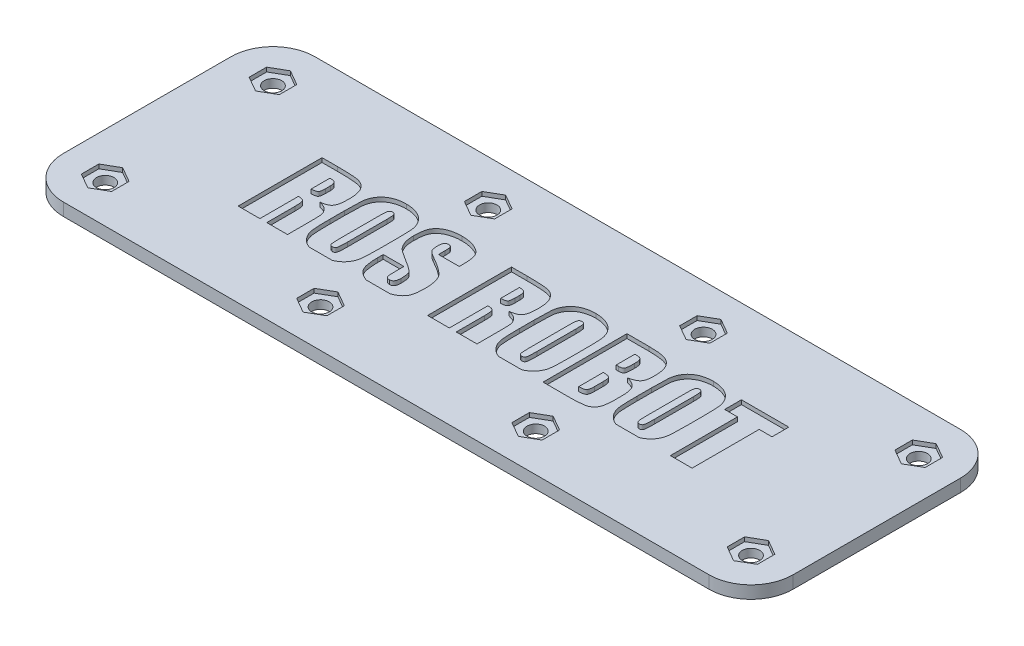
from build123d import *

# Parameters (mm, degrees)
SKETCH1_W           = 174
SKETCH1_H           = 60
BOSS_EXTRUDE1_DEPTH = 3
SKETCH2_R           = 2.09
CUT_EXTRUDE1_DEPTH  = 4
FILLET1_R           = 10
CUT_EXTRUDE2_DEPTH  = 1
CUT_EXTRUDE3_DEPTH  = 1


with BuildPart() as part:
    # Sketch1 → Boss-Extrude1 (new body)
    with BuildSketch(Plane(origin=(0, 0, 0), x_dir=(1, 0, 0), z_dir=(0, 1, 0))):
        Rectangle(SKETCH1_W, SKETCH1_H)
    extrude(amount=BOSS_EXTRUDE1_DEPTH)

    # Sketch2 → Cut-Extrude1 (cut, through all)
    with BuildSketch(Plane(origin=(0, 3, 0), x_dir=(1, 0, 0), z_dir=(0, 1, 0))):
        with Locations((-76.995, 20)):
            Circle(SKETCH2_R)
        with Locations((-25.665, 20)):
            Circle(SKETCH2_R)
        with Locations((25.665, 20)):
            Circle(SKETCH2_R)
        with Locations((76.995, 20)):
            Circle(SKETCH2_R)
    cut_extrude1 = extrude(amount=-CUT_EXTRUDE1_DEPTH, mode=Mode.SUBTRACT)

    # Mirror1: Cut-Extrude1 across plane
    add(cut_extrude1.mirror(Plane.XY), mode=Mode.SUBTRACT)

    # Fillet1
    fillet1_edges = [part.edges().sort_by_distance(p)[0] for p in [
        (87, 1.5, 30),
        (-87, 1.5, 30),
        (-87, 1.5, -30),
        (87, 1.5, -30),
    ]]
    fillet(fillet1_edges, radius=FILLET1_R)

    # Sketch3 → Cut-Extrude2 (cut)
    with BuildSketch(Plane(origin=(0, 3, 0), x_dir=(1, 0, 0), z_dir=(0, 1, 0))):
        with BuildLine():
            Line((-55.294117647, 10), (-55.294117647, -10))
            Line((-55.294117647, -10), (-50.117647059, -10))
            Line((-50.117647059, -10), (-50.117647059, -0.823529412))
            add(Edge.make_bspline(
                [(-48.470588235, -3.235294118), (-48.472761242, -2.989057045), (-48.472387298, -2.639023284), (-48.505158342, -2.198133437), (-48.532479629, -1.92557618), (-48.569704298, -1.691279038), (-48.610487711, -1.495733015), (-48.665731057, -1.339045986), (-48.72892158, -1.214559745), (-48.811250352, -1.114048439), (-48.923249449, -1.039006456), (-49.055008244, -0.967790447), (-49.216553319, -0.913344326), (-49.404406892, -0.87518001), (-49.706887916, -0.834016934), (-49.948360167, -0.824906739), (-50.117647059, -0.823529412)],
                knots=[0, 0, 0, 0, 0.208712059, 0.296134584, 0.374433717, 0.440652749, 0.497064647, 0.543362023, 0.580977914, 0.614871505, 0.652040686, 0.69429784, 0.741574127, 0.795734674, 0.856514492, 1, 1, 1, 1], degree=3))
            Line((-48.470588235, -3.235294118), (-48.470588235, -10))
            Line((-48.470588235, -10), (-43.529411765, -10))
            Line((-43.529411765, -10), (-43.529411765, -4.658088235))
            add(Edge.make_bspline(
                [(-46.408088235, 0.573529412), (-46.169175195, 0.50822747), (-45.822797374, 0.415734606), (-45.392366575, 0.25367086), (-45.117566143, 0.123930771), (-44.870917189, -0.007492588), (-44.65785979, -0.150360385), (-44.475013905, -0.301624252), (-44.280128786, -0.508899378), (-44.084325942, -0.769865918), (-43.889130105, -1.074726742), (-43.748038737, -1.369657122), (-43.665206597, -1.619897087), (-43.628706333, -1.846302243), (-43.597806292, -2.071507013), (-43.579140796, -2.357697691), (-43.560358753, -2.703267668), (-43.546626536, -3.107776257), (-43.529565282, -3.765806928), (-43.534845869, -4.289262628), (-43.529411765, -4.658088235)],
                knots=[0, 0, 0, 0, 0.110230182, 0.159227155, 0.204340897, 0.245320208, 0.283417653, 0.318243371, 0.350628895, 0.409719639, 0.463107288, 0.511383408, 0.554826309, 0.579739697, 0.613274558, 0.655916727, 0.707227072, 0.767225961, 0.835926031, 1, 1, 1, 1], degree=3))
            add(Edge.make_bspline(
                [(-43.529411765, 4.617647059), (-43.523559379, 4.265343442), (-43.547444952, 3.759926021), (-43.602480895, 3.118174034), (-43.67103257, 2.70757313), (-43.748929488, 2.343067112), (-43.846868698, 2.023021074), (-43.966655354, 1.751430904), (-44.105783368, 1.520874413), (-44.274381424, 1.32692517), (-44.474656502, 1.156423758), (-44.713189671, 1.010798238), (-44.984161555, 0.881436662), (-45.289554301, 0.77180459), (-45.764929016, 0.650898651), (-46.14354858, 0.594911695), (-46.408088235, 0.573529412)],
                knots=[0, 0, 0, 0, 0.183790359, 0.264137372, 0.336086755, 0.400975565, 0.458649469, 0.51049186, 0.555594521, 0.598692018, 0.644079697, 0.692369191, 0.744168131, 0.800636925, 0.861471696, 1, 1, 1, 1], degree=3))
            add(Edge.make_bspline(
                [(-51.566176471, 10), (-50.993819944, 10.002073268), (-50.173782937, 9.992522011), (-49.130967301, 9.961770188), (-48.461579038, 9.934349846), (-47.867125834, 9.893765625), (-47.348485673, 9.846902044), (-46.905287107, 9.793813546), (-46.526534008, 9.727924289), (-46.192709029, 9.642203621), (-45.884608598, 9.529610049), (-45.589803188, 9.3956181), (-45.311726309, 9.228198446), (-45.052332013, 9.031642664), (-44.802348856, 8.815602269), (-44.574834978, 8.564597704), (-44.355921653, 8.290441128), (-44.158035206, 7.977684947), (-43.990685169, 7.6226227), (-43.847046859, 7.226287928), (-43.730527587, 6.786918244), (-43.640302786, 6.30511939), (-43.54780148, 5.579003966), (-43.534831682, 5.009887783), (-43.529411765, 4.617647059)],
                knots=[0, 0, 0, 0, 0.148881435, 0.213302999, 0.271376625, 0.323137581, 0.368275921, 0.406826982, 0.439217091, 0.468211877, 0.496345732, 0.524443445, 0.552325136, 0.580568943, 0.609027807, 0.638127546, 0.668547056, 0.700208954, 0.734143472, 0.770447799, 0.809729999, 0.852243566, 0.897872275, 1, 1, 1, 1], degree=3))
            Line((-51.566176471, 10), (-55.294117647, 10))
        make_face()
        with BuildLine():
            Line((-50.117647059, 2.235294118), (-50.117647059, 6.705882353))
            add(Edge.make_bspline(
                [(-48.470588235, 5.154411765), (-48.473249493, 5.418336948), (-48.491488459, 5.788234319), (-48.648984539, 6.208983424), (-48.813415334, 6.422021915), (-49.050216126, 6.552252293), (-49.479623299, 6.691331049), (-49.853765331, 6.700787332), (-50.117647059, 6.705882353)],
                knots=[0, 0, 0, 0, 0.296724354, 0.405999103, 0.497474067, 0.590179394, 0.702696619, 1, 1, 1, 1], degree=3))
            Line((-48.470588235, 5.154411765), (-48.470588235, 4.047794118))
            add(Edge.make_bspline(
                [(-50.117647059, 2.235294118), (-49.857557508, 2.233760348), (-49.495937601, 2.254180117), (-49.069683976, 2.35845805), (-48.867432147, 2.445644692), (-48.745704681, 2.557108502), (-48.667446357, 2.67024801), (-48.608188606, 2.82039897), (-48.557138221, 3.001544455), (-48.518214815, 3.215789117), (-48.475786771, 3.567218376), (-48.476158421, 3.849445469), (-48.470588235, 4.047794118)],
                knots=[0, 0, 0, 0, 0.263190412, 0.361520604, 0.442777778, 0.481272857, 0.526534855, 0.58025477, 0.643242407, 0.716208439, 0.799608844, 1, 1, 1, 1], degree=3))
        make_face(mode=Mode.SUBTRACT)
        with BuildLine():
            add(Edge.make_bspline(
                [(-38.388878703, -10), (-38.434708827, -9.982163901), (-38.689460697, -9.879507335), (-39.133624425, -9.665315535), (-39.678873646, -9.294141109), (-40.171633435, -8.868283302), (-40.586226394, -8.369291591), (-40.935270304, -7.832606995), (-41.206143721, -7.264803658), (-41.399454988, -6.675518554), (-41.495658764, -6.158697296), (-41.535688973, -5.707416893), (-41.565020939, -5.309067923), (-41.590029598, -4.851864522), (-41.612869809, -4.338406349), (-41.625933126, -3.765971588), (-41.641510116, -2.887325956), (-41.645761355, -2.198537053), (-41.647058824, -1.720588235)],
                knots=[0.225245668, 0.225245668, 0.225245668, 0.225245668, 0.237119462, 0.291547555, 0.344026935, 0.396061673, 0.448382925, 0.500209986, 0.550407591, 0.599943185, 0.649656355, 0.677028621, 0.709391549, 0.746167788, 0.787661399, 0.833573904, 0.884512765, 1, 1, 1, 1], degree=3))
            Line((-38.388878703, -10), (-32.905924085, -10))
            add(Edge.make_bspline(
                [(-29.647058824, -1.720588235), (-29.651493202, -2.187493055), (-29.648984904, -2.861564549), (-29.662811581, -3.723176582), (-29.683877999, -4.286757999), (-29.699032895, -4.794372306), (-29.725932686, -5.247761941), (-29.754578926, -5.646171759), (-29.796123241, -6.101647454), (-29.881927971, -6.624914293), (-30.068550138, -7.219511222), (-30.333102923, -7.785177502), (-30.665158797, -8.321353326), (-31.070693344, -8.812589913), (-31.546395378, -9.246149672), (-32.087746262, -9.619888631), (-32.553134288, -9.856872129), (-32.833767769, -9.972014325), (-32.905924085, -10)],
                knots=[0, 0, 0, 0, 0.112808662, 0.162854343, 0.208179017, 0.249065094, 0.285542064, 0.317901769, 0.345566, 0.396043361, 0.445675688, 0.495616157, 0.546553387, 0.597655569, 0.64900077, 0.701564226, 0.756120432, 0.774811337, 0.774811337, 0.774811337, 0.774811337], degree=3))
            Line((-29.647058824, -1.720588235), (-29.647058824, 1.720588235))
            add(Edge.make_bspline(
                [(-35.647058824, 10.470588235), (-35.137575905, 10.469671201), (-34.387789186, 10.412760966), (-33.431941344, 10.186217725), (-32.774834164, 9.955436447), (-32.162941474, 9.66465689), (-31.615877667, 9.296369489), (-31.126285412, 8.866806687), (-30.711083667, 8.369636901), (-30.363430058, 7.831558235), (-30.087072885, 7.265823377), (-29.894586103, 6.674250061), (-29.797995226, 6.156263525), (-29.759895222, 5.70476117), (-29.722524292, 5.308199355), (-29.70625146, 4.85167531), (-29.680267762, 4.338451088), (-29.669795353, 3.76590889), (-29.643393387, 2.887460762), (-29.654649696, 2.198445293), (-29.647058824, 1.720588235)],
                knots=[0, 0, 0, 0, 0.123202067, 0.180742519, 0.236944207, 0.291252849, 0.34398818, 0.39581077, 0.448142032, 0.499979007, 0.550314461, 0.599859532, 0.649873316, 0.677250819, 0.709347809, 0.74611558, 0.787617129, 0.833538417, 0.884493047, 1, 1, 1, 1], degree=3))
            add(Edge.make_bspline(
                [(-41.647058824, 1.720588235), (-41.642479537, 2.188713716), (-41.645362429, 2.862798648), (-41.631084571, 3.724392091), (-41.610768004, 4.286786515), (-41.593370162, 4.795440173), (-41.573393836, 5.249142813), (-41.542621817, 5.647343808), (-41.502478839, 6.101980465), (-41.410876445, 6.624508136), (-41.225726568, 7.219419898), (-40.962205687, 7.784810836), (-40.626379301, 8.318154077), (-40.225023864, 8.814087979), (-39.744245108, 9.243388483), (-39.206325549, 9.621689493), (-38.599037538, 9.926923969), (-37.936810382, 10.175524458), (-36.95178636, 10.407114958), (-36.17714782, 10.475980227), (-35.647058824, 10.470588235)],
                knots=[0, 0, 0, 0, 0.113099886, 0.162847397, 0.208170127, 0.249054449, 0.28580995, 0.317873, 0.345536044, 0.396062444, 0.445692641, 0.495630967, 0.546314995, 0.597643479, 0.649205395, 0.701523382, 0.756077247, 0.812941755, 0.872040704, 1, 1, 1, 1], degree=3))
            Line((-41.647058824, 1.720588235), (-41.647058824, -1.720588235))
        make_face()
        with BuildLine():
            Line((-36.470588235, -4.566176471), (-36.470588235, 4.959558824))
            add(Edge.make_bspline(
                [(-35.621323529, 7.176470588), (-35.747602558, 7.182797441), (-35.932570128, 7.138559035), (-36.14071198, 7.000683728), (-36.24456145, 6.877108883), (-36.313521669, 6.744569909), (-36.354014493, 6.603411175), (-36.390824537, 6.425261242), (-36.417513223, 6.207467331), (-36.445299609, 5.951569919), (-36.461170767, 5.530700778), (-36.472983376, 5.196283974), (-36.470588235, 4.959558824)],
                knots=[0, 0, 0, 0, 0.141272891, 0.207933505, 0.278501019, 0.320511285, 0.375555263, 0.443280697, 0.525522512, 0.622694993, 0.733336158, 1, 1, 1, 1], degree=3))
            add(Edge.make_bspline(
                [(-34.823529412, 4.959558824), (-34.824206202, 5.175303354), (-34.830022252, 5.482932653), (-34.843021941, 5.871602904), (-34.862219357, 6.115480155), (-34.88386874, 6.32757554), (-34.907405438, 6.508580133), (-34.940578471, 6.655852623), (-34.986221663, 6.805984555), (-35.070163571, 6.954005969), (-35.268657855, 7.143059215), (-35.4859788, 7.172463444), (-35.621323529, 7.176470588)],
                knots=[0, 0, 0, 0, 0.245381507, 0.350013726, 0.44228014, 0.523562531, 0.592561096, 0.649714338, 0.695120491, 0.770678918, 0.840725622, 1, 1, 1, 1], degree=3))
            Line((-34.823529412, 4.959558824), (-34.823529412, -4.415441176))
            add(Edge.make_bspline(
                [(-35.658088235, -7.176470588), (-35.506517968, -7.179093019), (-35.270579792, -7.129538142), (-35.057506035, -6.90767097), (-34.978675403, -6.727494998), (-34.93172423, -6.545832046), (-34.90568827, -6.363169473), (-34.879563331, -6.140135689), (-34.857350345, -5.875330263), (-34.844662634, -5.568704581), (-34.82859228, -5.07734288), (-34.824982646, -4.688733938), (-34.823529412, -4.415441176)],
                knots=[0, 0, 0, 0, 0.145035585, 0.209346918, 0.281953002, 0.327186926, 0.385477675, 0.455016533, 0.53818829, 0.634996402, 0.743261766, 1, 1, 1, 1], degree=3))
            add(Edge.make_bspline(
                [(-36.470588235, -4.566176471), (-36.466064103, -4.834553498), (-36.468857925, -5.215756676), (-36.455213652, -5.695131762), (-36.434073907, -5.990199181), (-36.419382085, -6.243241553), (-36.392829647, -6.454082367), (-36.364986269, -6.62251498), (-36.325211771, -6.78643941), (-36.242673887, -6.945563097), (-36.032036263, -7.143111825), (-35.802728696, -7.175688722), (-35.658088235, -7.176470588)],
                knots=[0, 0, 0, 0, 0.263965983, 0.374910105, 0.471520145, 0.554902094, 0.624118814, 0.680393612, 0.722784308, 0.789641701, 0.853612109, 1, 1, 1, 1], degree=3))
        make_face(mode=Mode.SUBTRACT)
        with BuildLine():
            add(Edge.make_bspline(
                [(-24.797933292, -10), (-24.921932393, -9.95471233), (-25.178630769, -9.853998955), (-25.549413404, -9.667641606), (-25.909341849, -9.459149009), (-26.239594792, -9.236779668), (-26.536792154, -8.999076642), (-26.802666174, -8.749624779), (-27.036252757, -8.484168872), (-27.233897492, -8.202723929), (-27.407075044, -7.912631545), (-27.539510276, -7.599452016), (-27.648684303, -7.26533218), (-27.746477149, -6.902596374), (-27.819338969, -6.506054533), (-27.887643483, -6.077356452), (-27.937301298, -5.615945519), (-27.98785038, -4.93600571), (-27.999768306, -4.409440994), (-28, -4.047794118)],
                knots=[0.286183202, 0.286183202, 0.286183202, 0.286183202, 0.324626854, 0.366463546, 0.406943511, 0.445764357, 0.48234487, 0.51770616, 0.551866298, 0.585155068, 0.617796039, 0.650099364, 0.683972791, 0.720174947, 0.759459361, 0.801373688, 0.846639763, 0.894618483, 1, 1, 1, 1], degree=3))
            Line((-24.797933292, -10), (-19.023347482, -10))
            add(Edge.make_bspline(
                [(-16, -4.875), (-15.998014857, -5.212265147), (-16.014101673, -5.701000746), (-16.069510311, -6.326928981), (-16.122472292, -6.743414513), (-16.196896507, -7.123612972), (-16.283689692, -7.469046697), (-16.385871847, -7.780925616), (-16.507930807, -8.061015007), (-16.654822165, -8.317315274), (-16.830122643, -8.557450899), (-17.032306907, -8.789565117), (-17.265554656, -9.010265677), (-17.528122043, -9.221337336), (-17.822490556, -9.417622448), (-18.145436019, -9.60646373), (-18.543697705, -9.810536832), (-18.843273457, -9.934229978), (-19.023347482, -10)],
                knots=[0, 0, 0, 0, 0.107306702, 0.155458913, 0.199906966, 0.240819393, 0.278648167, 0.313173616, 0.345123698, 0.375689955, 0.406966721, 0.43957622, 0.473499712, 0.509002183, 0.546637541, 0.585960101, 0.627987093, 0.68893065, 0.68893065, 0.68893065, 0.68893065], degree=3))
            add(Edge.make_bspline(
                [(-16.9375, -0.566176471), (-16.77003858, -0.806043702), (-16.558891693, -1.211465721), (-16.357268829, -1.810580448), (-16.225991682, -2.324256078), (-16.123687479, -2.890649038), (-16.024389707, -3.744627839), (-15.999987273, -4.413744653), (-16, -4.875)],
                knots=[0, 0, 0, 0, 0.19599711, 0.304678492, 0.423526134, 0.551406495, 0.69050554, 1, 1, 1, 1], degree=3))
            add(Edge.make_bspline(
                [(-21.529411765, 2.783088235), (-20.970305965, 2.473367773), (-20.172909867, 2.018375264), (-19.189740388, 1.388063598), (-18.573813667, 0.956308764), (-18.038870295, 0.552231412), (-17.480460132, 0.067679288), (-17.119384349, -0.302443276), (-16.9375, -0.566176471)],
                knots=[0, 0, 0, 0, 0.335277756, 0.481299959, 0.612364063, 0.729738585, 0.83271341, 1, 1, 1, 1], degree=3))
            add(Edge.make_bspline(
                [(-23.044117647, 4.007352941), (-22.995337919, 3.908726816), (-22.89204074, 3.763485988), (-22.716456053, 3.578339598), (-22.539134867, 3.431720611), (-22.334418219, 3.274066191), (-21.999638416, 3.049218613), (-21.722308394, 2.892754352), (-21.529411765, 2.783088235)],
                knots=[0, 0, 0, 0, 0.16675308, 0.269572473, 0.387215686, 0.516181657, 0.662459423, 1, 1, 1, 1], degree=3))
            add(Edge.make_bspline(
                [(-23.294117647, 5.573529412), (-23.296326908, 5.268536496), (-23.266606811, 4.735456987), (-23.143358219, 4.213860364), (-23.044117647, 4.007352941)],
                knots=[0, 0, 0, 0, 0.572651319, 1, 1, 1, 1], degree=3))
            add(Edge.make_bspline(
                [(-22.272058824, 7.176470588), (-22.422382216, 7.175318321), (-22.652559624, 7.133916453), (-22.898626556, 6.956363272), (-23.049357016, 6.777858689), (-23.163822977, 6.547345801), (-23.266997244, 6.142731079), (-23.300706927, 5.81087743), (-23.294117647, 5.573529412)],
                knots=[0, 0, 0, 0, 0.212113464, 0.31285869, 0.41856281, 0.535755935, 0.669150346, 1, 1, 1, 1], degree=3))
            add(Edge.make_bspline(
                [(-21.411764706, 5.463235294), (-21.412660836, 5.76472571), (-21.419668964, 6.171441157), (-21.505234267, 6.643084782), (-21.592726876, 6.863837137), (-21.719331543, 7.011621902), (-21.93796031, 7.146205292), (-22.136537492, 7.180330892), (-22.272058824, 7.176470588)],
                knots=[0, 0, 0, 0, 0.412842651, 0.553103389, 0.653610262, 0.733180376, 0.814494127, 1, 1, 1, 1], degree=3))
            Line((-21.411764706, 5.463235294), (-21.411764706, 3.882352941))
            Line((-21.411764706, 3.882352941), (-16.470588235, 3.882352941))
            Line((-16.470588235, 3.882352941), (-16.470588235, 4.6875))
            add(Edge.make_bspline(
                [(-22.433823529, 10.470588235), (-22.099355515, 10.465692072), (-21.605258314, 10.457850903), (-20.964766066, 10.377003258), (-20.510624153, 10.311996602), (-20.077185548, 10.213326449), (-19.66128427, 10.101842278), (-19.265923032, 9.964972533), (-18.892354157, 9.80679878), (-18.543176622, 9.63523955), (-18.21927313, 9.457507477), (-17.933690102, 9.258320673), (-17.668603796, 9.061328877), (-17.446057148, 8.839147392), (-17.242755176, 8.616987473), (-17.078595902, 8.376988569), (-16.940479561, 8.122327535), (-16.830854918, 7.838398109), (-16.730671215, 7.519755184), (-16.652900473, 7.154877719), (-16.581526247, 6.748162273), (-16.532829806, 6.294893947), (-16.481907954, 5.603934437), (-16.470960066, 5.062596294), (-16.470588235, 4.6875)],
                knots=[0, 0, 0, 0, 0.103080501, 0.151693764, 0.19864086, 0.244219301, 0.288418896, 0.331125316, 0.372879908, 0.413199037, 0.450863398, 0.486435308, 0.520312869, 0.552324632, 0.583055083, 0.61287614, 0.641566415, 0.672036474, 0.706397787, 0.744284381, 0.786763637, 0.833460023, 0.88452287, 1, 1, 1, 1], degree=3))
            add(Edge.make_bspline(
                [(-28.235294118, 4.786764706), (-28.229904379, 5.148252189), (-28.222936356, 5.672108777), (-28.155500003, 6.342020821), (-28.091071009, 6.786560757), (-28.006245663, 7.192892425), (-27.906291969, 7.561802534), (-27.780339706, 7.889279126), (-27.639202273, 8.183003162), (-27.474416935, 8.448602585), (-27.285392797, 8.693163012), (-27.079329609, 8.929597443), (-26.842812469, 9.143134685), (-26.586901064, 9.347943873), (-26.308886347, 9.538843121), (-26.005284687, 9.71100803), (-25.56649327, 9.9259027), (-24.965093143, 10.146603568), (-23.885130997, 10.411380502), (-23.0240668, 10.470239671), (-22.433823529, 10.470588235)],
                knots=[0, 0, 0, 0, 0.115094371, 0.166420003, 0.214115061, 0.257929727, 0.298417601, 0.335563099, 0.369390983, 0.401957355, 0.434786392, 0.467650138, 0.501587937, 0.535990613, 0.571893796, 0.608743473, 0.646930183, 0.727243377, 0.811970216, 1, 1, 1, 1], degree=3))
            add(Edge.make_bspline(
                [(-23.977941176, -1.323529412), (-24.294511538, -1.131326069), (-24.746909058, -0.853590336), (-25.315671043, -0.487028948), (-25.67659423, -0.24587788), (-25.996353777, -0.028044889), (-26.270684916, 0.16966582), (-26.504121427, 0.345288928), (-26.757215062, 0.55675599), (-27.030741585, 0.83859719), (-27.322185819, 1.219607774), (-27.582496129, 1.657177863), (-27.816766684, 2.149881455), (-28.010855914, 2.707861537), (-28.187017003, 3.591825136), (-28.241857015, 4.295407074), (-28.235294118, 4.786764706)],
                knots=[0, 0, 0, 0, 0.139496641, 0.199928992, 0.254849813, 0.302989801, 0.34564832, 0.382206877, 0.412998417, 0.469793972, 0.529711152, 0.593277583, 0.661207422, 0.734923814, 0.815133371, 1, 1, 1, 1], degree=3))
            add(Edge.make_bspline(
                [(-21.422794118, -3.125), (-21.527957196, -3.006841113), (-21.723413246, -2.83159541), (-22.028603612, -2.599028882), (-22.320702285, -2.381572104), (-22.665243802, -2.146757406), (-23.218217274, -1.78459162), (-23.666055556, -1.51485041), (-23.977941176, -1.323529412)],
                knots=[0, 0, 0, 0, 0.151175118, 0.250666735, 0.367275691, 0.499710264, 0.649705358, 1, 1, 1, 1], degree=3))
            add(Edge.make_bspline(
                [(-20.941176471, -5.507352941), (-20.94089679, -5.230116988), (-20.953296851, -4.833443943), (-21.001304147, -4.330418615), (-21.057491677, -4.01300655), (-21.120630168, -3.732359951), (-21.227908005, -3.432060954), (-21.330213724, -3.231067844), (-21.422794118, -3.125)],
                knots=[0, 0, 0, 0, 0.336674091, 0.481823819, 0.613233997, 0.728041636, 0.830672596, 1, 1, 1, 1], degree=3))
            add(Edge.make_bspline(
                [(-22.055147059, -7.176470588), (-21.885541571, -7.181042695), (-21.636919353, -7.129696315), (-21.360636518, -6.948074167), (-21.204916613, -6.755008193), (-21.081823083, -6.513814138), (-20.968209931, -6.094777196), (-20.941233932, -5.750234712), (-20.941176471, -5.507352941)],
                knots=[0, 0, 0, 0, 0.223295666, 0.324626749, 0.430189395, 0.546595578, 0.679609164, 1, 1, 1, 1], degree=3))
            add(Edge.make_bspline(
                [(-23.058823529, -5.297794118), (-23.061330484, -5.479444625), (-23.049017381, -5.737799236), (-23.033549614, -6.065711905), (-23.004726, -6.271102852), (-22.979951789, -6.451745816), (-22.937095221, -6.603092758), (-22.895293432, -6.730061315), (-22.827664593, -6.862832994), (-22.711681339, -6.993662718), (-22.454353006, -7.150620917), (-22.215061065, -7.172923046), (-22.055147059, -7.176470588)],
                knots=[0, 0, 0, 0, 0.221449353, 0.31585969, 0.400263121, 0.474516094, 0.538002798, 0.591926172, 0.637412015, 0.719012888, 0.801608182, 1, 1, 1, 1], degree=3))
            Line((-23.058823529, -5.297794118), (-23.058823529, -2.705882353))
            Line((-23.058823529, -2.705882353), (-28, -2.705882353))
            Line((-28, -2.705882353), (-28, -4.047794118))
        make_face()
        with BuildLine():
            Line((-10.117647059, 10), (-10.117647059, -10))
            Line((-10.117647059, -10), (-4.941176471, -10))
            Line((-4.941176471, -10), (-4.941176471, -0.823529412))
            add(Edge.make_bspline(
                [(-3.294117647, -3.235294118), (-3.296290654, -2.989057045), (-3.295916709, -2.639023284), (-3.328687754, -2.198133437), (-3.356009041, -1.92557618), (-3.39323371, -1.691279038), (-3.434017123, -1.495733015), (-3.489260469, -1.339045986), (-3.552450992, -1.214559745), (-3.634779763, -1.114048439), (-3.74677886, -1.039006456), (-3.878537656, -0.967790447), (-4.040082731, -0.913344326), (-4.227936304, -0.87518001), (-4.530417327, -0.834016934), (-4.771889579, -0.824906739), (-4.941176471, -0.823529412)],
                knots=[0, 0, 0, 0, 0.208712059, 0.296134584, 0.374433717, 0.440652749, 0.497064647, 0.543362023, 0.580977914, 0.614871505, 0.652040686, 0.69429784, 0.741574127, 0.795734674, 0.856514492, 1, 1, 1, 1], degree=3))
            Line((-3.294117647, -3.235294118), (-3.294117647, -10))
            Line((-3.294117647, -10), (1.647058824, -10))
            Line((1.647058824, -10), (1.647058824, -4.658088235))
            add(Edge.make_bspline(
                [(-1.231617647, 0.573529412), (-0.992704607, 0.50822747), (-0.646326786, 0.415734606), (-0.215895987, 0.25367086), (0.058904445, 0.123930771), (0.3055534, -0.007492588), (0.518610798, -0.150360385), (0.701456683, -0.301624252), (0.896341803, -0.508899378), (1.092144646, -0.769865918), (1.287340483, -1.074726742), (1.428431851, -1.369657122), (1.511263992, -1.619897087), (1.547764255, -1.846302243), (1.578664296, -2.071507013), (1.597329792, -2.357697691), (1.616111835, -2.703267668), (1.629844053, -3.107776257), (1.646905306, -3.765806928), (1.641624719, -4.289262628), (1.647058824, -4.658088235)],
                knots=[0, 0, 0, 0, 0.110230182, 0.159227155, 0.204340897, 0.245320208, 0.283417653, 0.318243371, 0.350628895, 0.409719639, 0.463107288, 0.511383408, 0.554826309, 0.579739697, 0.613274558, 0.655916727, 0.707227072, 0.767225961, 0.835926031, 1, 1, 1, 1], degree=3))
            add(Edge.make_bspline(
                [(1.647058824, 4.617647059), (1.652911209, 4.265343442), (1.629025636, 3.759926021), (1.573989693, 3.118174034), (1.505438018, 2.70757313), (1.4275411, 2.343067112), (1.32960189, 2.023021074), (1.209815234, 1.751430904), (1.070687221, 1.520874413), (0.902089165, 1.32692517), (0.701814086, 1.156423758), (0.463280917, 1.010798238), (0.192309033, 0.881436662), (-0.113083713, 0.77180459), (-0.588458428, 0.650898651), (-0.967077992, 0.594911695), (-1.231617647, 0.573529412)],
                knots=[0, 0, 0, 0, 0.183790359, 0.264137372, 0.336086755, 0.400975565, 0.458649469, 0.51049186, 0.555594521, 0.598692018, 0.644079697, 0.692369191, 0.744168131, 0.800636925, 0.861471696, 1, 1, 1, 1], degree=3))
            add(Edge.make_bspline(
                [(-6.389705882, 10), (-5.817349355, 10.002073268), (-4.997312349, 9.992522011), (-3.954496712, 9.961770188), (-3.28510845, 9.934349846), (-2.690655246, 9.893765625), (-2.172015085, 9.846902044), (-1.728816518, 9.793813546), (-1.35006342, 9.727924289), (-1.016238441, 9.642203621), (-0.70813801, 9.529610049), (-0.4133326, 9.3956181), (-0.135255721, 9.228198446), (0.124138575, 9.031642664), (0.374121732, 8.815602269), (0.60163561, 8.564597704), (0.820548935, 8.290441128), (1.018435383, 7.977684947), (1.185785419, 7.6226227), (1.329423729, 7.226287928), (1.445943001, 6.786918244), (1.536167802, 6.30511939), (1.628669108, 5.579003966), (1.641638907, 5.009887783), (1.647058824, 4.617647059)],
                knots=[0, 0, 0, 0, 0.148881435, 0.213302999, 0.271376625, 0.323137581, 0.368275921, 0.406826982, 0.439217091, 0.468211877, 0.496345732, 0.524443445, 0.552325136, 0.580568943, 0.609027807, 0.638127546, 0.668547056, 0.700208954, 0.734143472, 0.770447799, 0.809729999, 0.852243566, 0.897872275, 1, 1, 1, 1], degree=3))
            Line((-6.389705882, 10), (-10.117647059, 10))
        make_face()
        with BuildLine():
            Line((-4.941176471, 2.235294118), (-4.941176471, 6.705882353))
            add(Edge.make_bspline(
                [(-3.294117647, 5.154411765), (-3.296778905, 5.418336948), (-3.315017871, 5.788234319), (-3.472513951, 6.208983424), (-3.636944745, 6.422021915), (-3.873745538, 6.552252293), (-4.303152711, 6.691331049), (-4.677294743, 6.700787332), (-4.941176471, 6.705882353)],
                knots=[0, 0, 0, 0, 0.296724354, 0.405999103, 0.497474067, 0.590179394, 0.702696619, 1, 1, 1, 1], degree=3))
            Line((-3.294117647, 5.154411765), (-3.294117647, 4.047794118))
            add(Edge.make_bspline(
                [(-4.941176471, 2.235294118), (-4.681086919, 2.233760348), (-4.319467013, 2.254180117), (-3.893213388, 2.35845805), (-3.690961559, 2.445644692), (-3.569234093, 2.557108502), (-3.490975769, 2.67024801), (-3.431718018, 2.82039897), (-3.380667632, 3.001544455), (-3.341744227, 3.215789117), (-3.299316183, 3.567218376), (-3.299687833, 3.849445469), (-3.294117647, 4.047794118)],
                knots=[0, 0, 0, 0, 0.263190412, 0.361520604, 0.442777778, 0.481272857, 0.526534855, 0.58025477, 0.643242407, 0.716208439, 0.799608844, 1, 1, 1, 1], degree=3))
        make_face(mode=Mode.SUBTRACT)
        with BuildLine():
            add(Edge.make_bspline(
                [(6.787591886, -10), (6.741761761, -9.982163901), (6.487009891, -9.879507335), (6.042846164, -9.665315535), (5.497596942, -9.294141109), (5.004837153, -8.868283302), (4.590244195, -8.369291591), (4.241200285, -7.832606995), (3.970326867, -7.264803658), (3.7770156, -6.675518554), (3.680811824, -6.158697296), (3.640781616, -5.707416893), (3.61144965, -5.309067923), (3.58644099, -4.851864522), (3.563600779, -4.338406349), (3.550537462, -3.765971588), (3.534960472, -2.887325956), (3.530709234, -2.198537053), (3.529411765, -1.720588235)],
                knots=[0.225245668, 0.225245668, 0.225245668, 0.225245668, 0.237119462, 0.291547555, 0.344026935, 0.396061673, 0.448382925, 0.500209986, 0.550407591, 0.599943185, 0.649656355, 0.677028621, 0.709391549, 0.746167788, 0.787661399, 0.833573904, 0.884512765, 1, 1, 1, 1], degree=3))
            Line((6.787591886, -10), (12.270546503, -10))
            add(Edge.make_bspline(
                [(15.529411765, -1.720588235), (15.524977386, -2.187493055), (15.527485684, -2.861564549), (15.513659007, -3.723176582), (15.492592589, -4.286757999), (15.477437693, -4.794372306), (15.450537902, -5.247761941), (15.421891662, -5.646171759), (15.380347347, -6.101647454), (15.294542618, -6.624914293), (15.107920451, -7.219511222), (14.843367666, -7.785177502), (14.511311791, -8.321353326), (14.105777244, -8.812589913), (13.63007521, -9.246149672), (13.088724326, -9.619888631), (12.6233363, -9.856872129), (12.342702819, -9.972014325), (12.270546503, -10)],
                knots=[0, 0, 0, 0, 0.112808662, 0.162854343, 0.208179017, 0.249065094, 0.285542064, 0.317901769, 0.345566, 0.396043361, 0.445675688, 0.495616157, 0.546553387, 0.597655569, 0.64900077, 0.701564226, 0.756120432, 0.774811337, 0.774811337, 0.774811337, 0.774811337], degree=3))
            Line((15.529411765, -1.720588235), (15.529411765, 1.720588235))
            add(Edge.make_bspline(
                [(9.529411765, 10.470588235), (10.038894684, 10.469671201), (10.788681402, 10.412760966), (11.744529245, 10.186217725), (12.401636425, 9.955436447), (13.013529114, 9.66465689), (13.560592921, 9.296369489), (14.050185177, 8.866806687), (14.465386921, 8.369636901), (14.81304053, 7.831558235), (15.089397703, 7.265823377), (15.281884485, 6.674250061), (15.378475362, 6.156263525), (15.416575366, 5.70476117), (15.453946296, 5.308199355), (15.470219128, 4.85167531), (15.496202826, 4.338451088), (15.506675236, 3.76590889), (15.533077201, 2.887460762), (15.521820892, 2.198445293), (15.529411765, 1.720588235)],
                knots=[0, 0, 0, 0, 0.123202067, 0.180742519, 0.236944207, 0.291252849, 0.34398818, 0.39581077, 0.448142032, 0.499979007, 0.550314461, 0.599859532, 0.649873316, 0.677250819, 0.709347809, 0.74611558, 0.787617129, 0.833538417, 0.884493047, 1, 1, 1, 1], degree=3))
            add(Edge.make_bspline(
                [(3.529411765, 1.720588235), (3.533991052, 2.188713716), (3.531108159, 2.862798648), (3.545386018, 3.724392091), (3.565702585, 4.286786515), (3.583100426, 4.795440173), (3.603076752, 5.249142813), (3.633848772, 5.647343808), (3.67399175, 6.101980465), (3.765594143, 6.624508136), (3.95074402, 7.219419898), (4.214264902, 7.784810836), (4.550091288, 8.318154077), (4.951446724, 8.814087979), (5.43222548, 9.243388483), (5.97014504, 9.621689493), (6.57743305, 9.926923969), (7.239660206, 10.175524458), (8.224684229, 10.407114958), (8.999322768, 10.475980227), (9.529411765, 10.470588235)],
                knots=[0, 0, 0, 0, 0.113099886, 0.162847397, 0.208170127, 0.249054449, 0.28580995, 0.317873, 0.345536044, 0.396062444, 0.445692641, 0.495630967, 0.546314995, 0.597643479, 0.649205395, 0.701523382, 0.756077247, 0.812941755, 0.872040704, 1, 1, 1, 1], degree=3))
            Line((3.529411765, 1.720588235), (3.529411765, -1.720588235))
        make_face()
        with BuildLine():
            Line((8.705882353, -4.566176471), (8.705882353, 4.959558824))
            add(Edge.make_bspline(
                [(9.555147059, 7.176470588), (9.428868031, 7.182797441), (9.24390046, 7.138559035), (9.035758608, 7.000683728), (8.931909138, 6.877108883), (8.862948919, 6.744569909), (8.822456095, 6.603411175), (8.785646052, 6.425261242), (8.758957365, 6.207467331), (8.73117098, 5.951569919), (8.715299821, 5.530700778), (8.703487212, 5.196283974), (8.705882353, 4.959558824)],
                knots=[0, 0, 0, 0, 0.141272891, 0.207933505, 0.278501019, 0.320511285, 0.375555263, 0.443280697, 0.525522512, 0.622694993, 0.733336158, 1, 1, 1, 1], degree=3))
            add(Edge.make_bspline(
                [(10.352941176, 4.959558824), (10.352264386, 5.175303354), (10.346448336, 5.482932653), (10.333448647, 5.871602904), (10.314251231, 6.115480155), (10.292601849, 6.32757554), (10.26906515, 6.508580133), (10.235892117, 6.655852623), (10.190248925, 6.805984555), (10.106307017, 6.954005969), (9.907812734, 7.143059215), (9.690491789, 7.172463444), (9.555147059, 7.176470588)],
                knots=[0, 0, 0, 0, 0.245381507, 0.350013726, 0.44228014, 0.523562531, 0.592561096, 0.649714338, 0.695120491, 0.770678918, 0.840725622, 1, 1, 1, 1], degree=3))
            Line((10.352941176, 4.959558824), (10.352941176, -4.415441176))
            add(Edge.make_bspline(
                [(9.518382353, -7.176470588), (9.66995262, -7.179093019), (9.905890797, -7.129538142), (10.118964553, -6.90767097), (10.197795186, -6.727494998), (10.244746358, -6.545832046), (10.270782318, -6.363169473), (10.296907257, -6.140135689), (10.319120243, -5.875330263), (10.331807954, -5.568704581), (10.347878308, -5.07734288), (10.351487943, -4.688733938), (10.352941176, -4.415441176)],
                knots=[0, 0, 0, 0, 0.145035585, 0.209346918, 0.281953002, 0.327186926, 0.385477675, 0.455016533, 0.53818829, 0.634996402, 0.743261766, 1, 1, 1, 1], degree=3))
            add(Edge.make_bspline(
                [(8.705882353, -4.566176471), (8.710406485, -4.834553498), (8.707612663, -5.215756676), (8.721256936, -5.695131762), (8.742396681, -5.990199181), (8.757088503, -6.243241553), (8.783640941, -6.454082367), (8.811484319, -6.62251498), (8.851258818, -6.78643941), (8.933796701, -6.945563097), (9.144434325, -7.143111825), (9.373741892, -7.175688722), (9.518382353, -7.176470588)],
                knots=[0, 0, 0, 0, 0.263965983, 0.374910105, 0.471520145, 0.554902094, 0.624118814, 0.680393612, 0.722784308, 0.789641701, 0.853612109, 1, 1, 1, 1], degree=3))
        make_face(mode=Mode.SUBTRACT)
        with BuildLine():
            Line((17.411764706, 10), (17.411764706, -10))
            Line((17.411764706, -10), (23.492647059, -10))
            add(Edge.make_bspline(
                [(29.647058824, -5.242647059), (29.646934914, -5.56266215), (29.63497194, -6.026795982), (29.584977204, -6.622276843), (29.53416178, -7.01986255), (29.468709895, -7.384541811), (29.388508503, -7.716304337), (29.293798242, -8.015418252), (29.149573113, -8.363197067), (28.927560807, -8.74691581), (28.580556243, -9.13068276), (28.16551384, -9.437763787), (27.757437565, -9.624746944), (27.37556001, -9.732935722), (27.017915035, -9.80554901), (26.59446752, -9.866667644), (26.10218982, -9.911528453), (25.545803904, -9.952303985), (24.668406884, -9.993965557), (23.976672129, -9.994581299), (23.492647059, -10)],
                knots=[0, 0, 0, 0, 0.102249571, 0.148224941, 0.190863369, 0.230259752, 0.266534441, 0.299841642, 0.330380545, 0.386717901, 0.440498022, 0.494529809, 0.550587574, 0.582802206, 0.621195561, 0.667097519, 0.719418425, 0.779085769, 0.845327487, 1, 1, 1, 1], degree=3))
            Line((29.647058824, -5.242647059), (29.647058824, -3.363970588))
            add(Edge.make_bspline(
                [(26.632352941, 0.941176471), (26.906401285, 0.878367085), (27.300653812, 0.765704813), (27.787692795, 0.562963036), (28.106692167, 0.402419875), (28.388685462, 0.220959582), (28.635442208, 0.022849809), (28.848962578, -0.191232265), (29.023773677, -0.428407061), (29.173198265, -0.68773403), (29.30233921, -0.975620533), (29.406624653, -1.296799727), (29.495483711, -1.649218696), (29.564266695, -2.032454679), (29.628905941, -2.607265288), (29.645716704, -3.054823478), (29.647058824, -3.363970588)],
                knots=[0, 0, 0, 0, 0.144065397, 0.209341867, 0.269975095, 0.326732211, 0.380743663, 0.431785064, 0.481119172, 0.531178616, 0.584838818, 0.642398889, 0.703899801, 0.770874214, 0.841643912, 1, 1, 1, 1], degree=3))
            add(Edge.make_bspline(
                [(29.411764706, 4.393382353), (29.416072307, 4.126960997), (29.396065876, 3.74315812), (29.335162444, 3.256001615), (29.279024495, 2.936656591), (29.198004913, 2.651763218), (29.102620539, 2.397408381), (28.989683638, 2.175311926), (28.854039324, 1.981642317), (28.690429234, 1.812181884), (28.495593314, 1.657001481), (28.269341956, 1.510833787), (28.006048053, 1.37965403), (27.71371462, 1.248439101), (27.252486443, 1.096633591), (26.888805185, 0.993582451), (26.632352941, 0.941176471)],
                knots=[0, 0, 0, 0, 0.159593497, 0.229911515, 0.294149678, 0.353664097, 0.407125896, 0.456720642, 0.50256341, 0.548270697, 0.597357213, 0.651540418, 0.709344876, 0.773469607, 0.843372266, 1, 1, 1, 1], degree=3))
            add(Edge.make_bspline(
                [(22.716911765, 10), (23.110299522, 9.995507602), (23.681885346, 9.991990426), (24.418574897, 9.952815753), (24.913450102, 9.906680869), (25.371467166, 9.85836305), (25.790704796, 9.791308442), (26.172459453, 9.715347075), (26.520787705, 9.627485478), (26.84146812, 9.519137488), (27.144180179, 9.391831518), (27.429336701, 9.235748238), (27.697604709, 9.054575482), (27.953304968, 8.851805073), (28.191702458, 8.62386534), (28.413756391, 8.371324932), (28.621706622, 8.093999736), (28.812626294, 7.782522973), (28.973440584, 7.426443305), (29.107426233, 7.026703693), (29.222906801, 6.585043099), (29.303426476, 6.098623186), (29.390288895, 5.365364626), (29.415704121, 4.790976826), (29.411764706, 4.393382353)],
                knots=[0, 0, 0, 0, 0.114402272, 0.166147642, 0.214440873, 0.258905608, 0.300029633, 0.337835121, 0.3720588, 0.404397908, 0.436166631, 0.467419606, 0.498747648, 0.530188964, 0.562196583, 0.594510161, 0.627862043, 0.662877889, 0.700506647, 0.74118522, 0.785347679, 0.833090934, 0.884403879, 1, 1, 1, 1], degree=3))
            Line((22.716911765, 10), (17.411764706, 10))
        make_face()
        with BuildLine():
            Line((22.588235294, -6.705882353), (22.588235294, -0.823529412))
            add(Edge.make_bspline(
                [(24.470588235, -2.783088235), (24.469862246, -2.581049271), (24.468263551, -2.292776904), (24.427029649, -1.932486797), (24.404272556, -1.709794577), (24.356722032, -1.522790473), (24.308770024, -1.366819262), (24.246387911, -1.243993471), (24.173743985, -1.146988974), (24.074721587, -1.077498638), (23.954129928, -1.015414588), (23.799805517, -0.965596267), (23.616507623, -0.922557764), (23.402762748, -0.886516164), (23.057457797, -0.845450875), (22.782095648, -0.830589633), (22.588235294, -0.823529412)],
                knots=[0, 0, 0, 0, 0.182450376, 0.259089149, 0.327073499, 0.383894219, 0.4328162, 0.473836669, 0.507662291, 0.540813339, 0.581833808, 0.629708737, 0.686529456, 0.751567122, 0.825033248, 1, 1, 1, 1], degree=3))
            Line((24.470588235, -2.783088235), (24.470588235, -4.746323529))
            add(Edge.make_bspline(
                [(22.588235294, -6.705882353), (22.772111176, -6.697406963), (23.035946818, -6.686457893), (23.366082308, -6.639035107), (23.574317755, -6.600446567), (23.754734821, -6.548534402), (23.909241043, -6.49114772), (24.037582, -6.426347928), (24.139518515, -6.345276863), (24.219828968, -6.242534291), (24.290452462, -6.116974085), (24.343026299, -5.957931043), (24.390391907, -5.772581816), (24.426658548, -5.55735456), (24.460433346, -5.212848849), (24.475325771, -4.93910161), (24.470588235, -4.746323529)],
                knots=[0, 0, 0, 0, 0.168587072, 0.241054147, 0.305044923, 0.362185481, 0.412580102, 0.455716051, 0.493190485, 0.530664919, 0.574336739, 0.624343173, 0.683356267, 0.749349201, 0.823767794, 1, 1, 1, 1], degree=3))
        make_face(mode=Mode.SUBTRACT)
        with BuildLine():
            Line((22.588235294, 2.235294118), (22.588235294, 6.705882353))
            add(Edge.make_bspline(
                [(24.470588235, 4.794117647), (24.472484496, 5.063219136), (24.456102942, 5.432680133), (24.377118595, 5.876003573), (24.290960876, 6.108918073), (24.185117865, 6.287925027), (24.065630734, 6.427443722), (23.932108439, 6.534581277), (23.771096212, 6.604626256), (23.56915719, 6.646964309), (23.171954505, 6.69359434), (22.835840675, 6.701690154), (22.588235294, 6.705882353)],
                knots=[0, 0, 0, 0, 0.247893338, 0.340015611, 0.413628261, 0.475403061, 0.530639967, 0.582137883, 0.631666993, 0.690827129, 0.771639487, 1, 1, 1, 1], degree=3))
            add(Edge.make_bspline(
                [(23.161764706, 2.246323529), (23.394028214, 2.2431048), (23.720403071, 2.271138301), (24.083618428, 2.440239428), (24.230880072, 2.592576437), (24.301784115, 2.75375132), (24.348188684, 2.915615042), (24.382075121, 3.121889263), (24.415674107, 3.370608152), (24.440054223, 3.665115429), (24.465440646, 4.144235023), (24.470464317, 4.52570717), (24.470588235, 4.794117647)],
                knots=[0, 0, 0, 0, 0.207123309, 0.283931547, 0.350841284, 0.389256939, 0.439128512, 0.499893306, 0.574453467, 0.661745219, 0.761896218, 1, 1, 1, 1], degree=3))
            add(Edge.make_bspline(
                [(22.588235294, 2.235294118), (22.874959549, 2.242972169), (23.161764706, 2.246323529)],
                knots=[0, 0, 0, 1, 1, 1], degree=2))
        make_face(mode=Mode.SUBTRACT)
        with BuildLine():
            add(Edge.make_bspline(
                [(34.787591886, -10), (34.741761761, -9.982163901), (34.487009891, -9.879507335), (34.042846164, -9.665315535), (33.497596942, -9.294141109), (33.004837153, -8.868283302), (32.590244195, -8.369291591), (32.241200285, -7.832606995), (31.970326867, -7.264803658), (31.7770156, -6.675518554), (31.680811824, -6.158697296), (31.640781616, -5.707416893), (31.61144965, -5.309067923), (31.58644099, -4.851864522), (31.563600779, -4.338406349), (31.550537462, -3.765971588), (31.534960472, -2.887325956), (31.530709234, -2.198537053), (31.529411765, -1.720588235)],
                knots=[0.225245668, 0.225245668, 0.225245668, 0.225245668, 0.237119462, 0.291547555, 0.344026935, 0.396061673, 0.448382925, 0.500209986, 0.550407591, 0.599943185, 0.649656355, 0.677028621, 0.709391549, 0.746167788, 0.787661399, 0.833573904, 0.884512765, 1, 1, 1, 1], degree=3))
            Line((34.787591886, -10), (40.270546503, -10))
            add(Edge.make_bspline(
                [(43.529411765, -1.720588235), (43.524977386, -2.187493055), (43.527485684, -2.861564549), (43.513659007, -3.723176582), (43.492592589, -4.286757999), (43.477437693, -4.794372306), (43.450537902, -5.247761941), (43.421891662, -5.646171759), (43.380347347, -6.101647454), (43.294542618, -6.624914293), (43.107920451, -7.219511222), (42.843367666, -7.785177502), (42.511311791, -8.321353326), (42.105777244, -8.812589913), (41.63007521, -9.246149672), (41.088724326, -9.619888631), (40.6233363, -9.856872129), (40.342702819, -9.972014325), (40.270546503, -10)],
                knots=[0, 0, 0, 0, 0.112808662, 0.162854343, 0.208179017, 0.249065094, 0.285542064, 0.317901769, 0.345566, 0.396043361, 0.445675688, 0.495616157, 0.546553387, 0.597655569, 0.64900077, 0.701564226, 0.756120432, 0.774811337, 0.774811337, 0.774811337, 0.774811337], degree=3))
            Line((43.529411765, -1.720588235), (43.529411765, 1.720588235))
            add(Edge.make_bspline(
                [(37.529411765, 10.470588235), (38.038894684, 10.469671201), (38.788681402, 10.412760966), (39.744529245, 10.186217725), (40.401636425, 9.955436447), (41.013529114, 9.66465689), (41.560592921, 9.296369489), (42.050185177, 8.866806687), (42.465386921, 8.369636901), (42.81304053, 7.831558235), (43.089397703, 7.265823377), (43.281884485, 6.674250061), (43.378475362, 6.156263525), (43.416575366, 5.70476117), (43.453946296, 5.308199355), (43.470219128, 4.85167531), (43.496202826, 4.338451088), (43.506675236, 3.76590889), (43.533077201, 2.887460762), (43.521820892, 2.198445293), (43.529411765, 1.720588235)],
                knots=[0, 0, 0, 0, 0.123202067, 0.180742519, 0.236944207, 0.291252849, 0.34398818, 0.39581077, 0.448142032, 0.499979007, 0.550314461, 0.599859532, 0.649873316, 0.677250819, 0.709347809, 0.74611558, 0.787617129, 0.833538417, 0.884493047, 1, 1, 1, 1], degree=3))
            add(Edge.make_bspline(
                [(31.529411765, 1.720588235), (31.533991052, 2.188713716), (31.531108159, 2.862798648), (31.545386018, 3.724392091), (31.565702585, 4.286786515), (31.583100426, 4.795440173), (31.603076752, 5.249142813), (31.633848772, 5.647343808), (31.67399175, 6.101980465), (31.765594143, 6.624508136), (31.95074402, 7.219419898), (32.214264902, 7.784810836), (32.550091288, 8.318154077), (32.951446724, 8.814087979), (33.43222548, 9.243388483), (33.97014504, 9.621689493), (34.57743305, 9.926923969), (35.239660206, 10.175524458), (36.224684229, 10.407114958), (36.999322768, 10.475980227), (37.529411765, 10.470588235)],
                knots=[0, 0, 0, 0, 0.113099886, 0.162847397, 0.208170127, 0.249054449, 0.28580995, 0.317873, 0.345536044, 0.396062444, 0.445692641, 0.495630967, 0.546314995, 0.597643479, 0.649205395, 0.701523382, 0.756077247, 0.812941755, 0.872040704, 1, 1, 1, 1], degree=3))
            Line((31.529411765, 1.720588235), (31.529411765, -1.720588235))
        make_face()
        with BuildLine():
            Line((36.705882353, -4.566176471), (36.705882353, 4.959558824))
            add(Edge.make_bspline(
                [(37.555147059, 7.176470588), (37.428868031, 7.182797441), (37.24390046, 7.138559035), (37.035758608, 7.000683728), (36.931909138, 6.877108883), (36.862948919, 6.744569909), (36.822456095, 6.603411175), (36.785646052, 6.425261242), (36.758957365, 6.207467331), (36.73117098, 5.951569919), (36.715299821, 5.530700778), (36.703487212, 5.196283974), (36.705882353, 4.959558824)],
                knots=[0, 0, 0, 0, 0.141272891, 0.207933505, 0.278501019, 0.320511285, 0.375555263, 0.443280697, 0.525522512, 0.622694993, 0.733336158, 1, 1, 1, 1], degree=3))
            add(Edge.make_bspline(
                [(38.352941176, 4.959558824), (38.352264386, 5.175303354), (38.346448336, 5.482932653), (38.333448647, 5.871602904), (38.314251231, 6.115480155), (38.292601849, 6.32757554), (38.26906515, 6.508580133), (38.235892117, 6.655852623), (38.190248925, 6.805984555), (38.106307017, 6.954005969), (37.907812734, 7.143059215), (37.690491789, 7.172463444), (37.555147059, 7.176470588)],
                knots=[0, 0, 0, 0, 0.245381507, 0.350013726, 0.44228014, 0.523562531, 0.592561096, 0.649714338, 0.695120491, 0.770678918, 0.840725622, 1, 1, 1, 1], degree=3))
            Line((38.352941176, 4.959558824), (38.352941176, -4.415441176))
            add(Edge.make_bspline(
                [(37.518382353, -7.176470588), (37.66995262, -7.179093019), (37.905890797, -7.129538142), (38.118964553, -6.90767097), (38.197795186, -6.727494998), (38.244746358, -6.545832046), (38.270782318, -6.363169473), (38.296907257, -6.140135689), (38.319120243, -5.875330263), (38.331807954, -5.568704581), (38.347878308, -5.07734288), (38.351487943, -4.688733938), (38.352941176, -4.415441176)],
                knots=[0, 0, 0, 0, 0.145035585, 0.209346918, 0.281953002, 0.327186926, 0.385477675, 0.455016533, 0.53818829, 0.634996402, 0.743261766, 1, 1, 1, 1], degree=3))
            add(Edge.make_bspline(
                [(36.705882353, -4.566176471), (36.710406485, -4.834553498), (36.707612663, -5.215756676), (36.721256936, -5.695131762), (36.742396681, -5.990199181), (36.757088503, -6.243241553), (36.783640941, -6.454082367), (36.811484319, -6.62251498), (36.851258818, -6.78643941), (36.933796701, -6.945563097), (37.144434325, -7.143111825), (37.373741892, -7.175688722), (37.518382353, -7.176470588)],
                knots=[0, 0, 0, 0, 0.263965983, 0.374910105, 0.471520145, 0.554902094, 0.624118814, 0.680393612, 0.722784308, 0.789641701, 0.853612109, 1, 1, 1, 1], degree=3))
        make_face(mode=Mode.SUBTRACT)
        Polygon((47.764705882, 6), (47.764705882, -10), (52.941176471, -10), (52.941176471, 6), (56, 6), (56, 10), (44.705882353, 10), (44.705882353, 6), align=None)
    extrude(amount=-CUT_EXTRUDE2_DEPTH, mode=Mode.SUBTRACT)

    # Sketch4 → Cut-Extrude3 (cut)
    with BuildSketch(Plane(origin=(0, 3, 0), x_dir=(1, 0, 0), z_dir=(0, 1, 0))):
        Polygon((-76.995, 15.843078062), (-73.395, 17.921539031), (-73.395, 22.078460969), (-76.995, 24.156921938), (-80.595, 22.078460969), (-80.595, 17.921539031), align=None)
        Polygon((-25.665, 15.843078062), (-22.065, 17.921539031), (-22.065, 22.078460969), (-25.665, 24.156921938), (-29.265, 22.078460969), (-29.265, 17.921539031), align=None)
        Polygon((25.665, 15.843078062), (29.265, 17.921539031), (29.265, 22.078460969), (25.665, 24.156921938), (22.065, 22.078460969), (22.065, 17.921539031), align=None)
        Polygon((76.995, 15.843078062), (80.595, 17.921539031), (80.595, 22.078460969), (76.995, 24.156921938), (73.395, 22.078460969), (73.395, 17.921539031), align=None)
    cut_extrude3 = extrude(amount=-CUT_EXTRUDE3_DEPTH, mode=Mode.SUBTRACT)

    # Mirror2: Cut-Extrude3 across plane
    add(cut_extrude3.mirror(Plane.XY), mode=Mode.SUBTRACT)


solid = part.part
